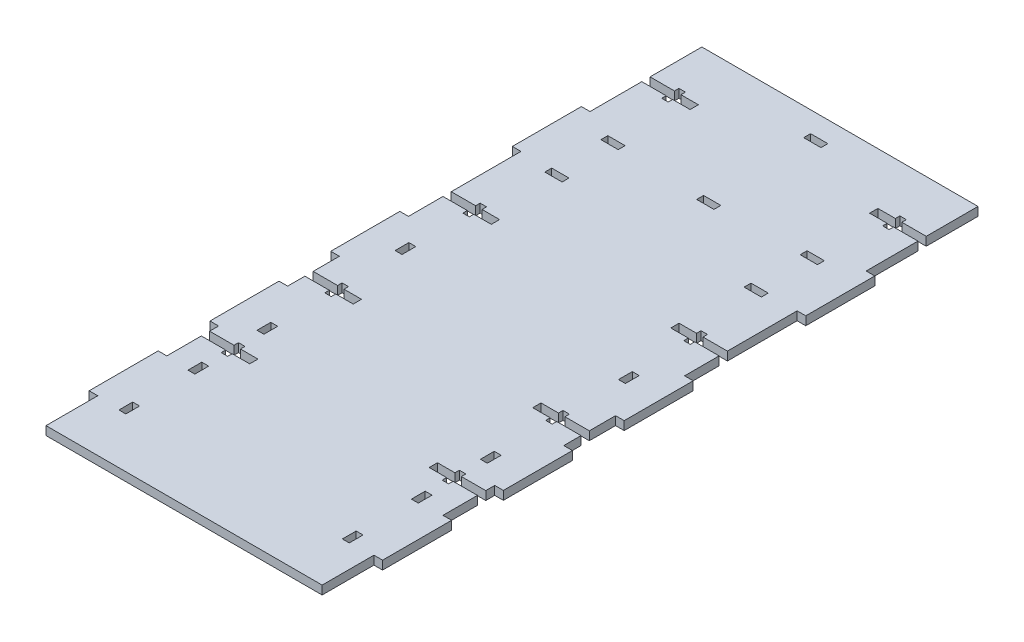
from build123d import *

# Parameters (mm, degrees)
SKETCH1_W           = 101.6
SKETCH1_H           = 241.3
BOSS_EXTRUDE1_DEPTH = 3.175
SKETCH2_W           = 2.54
SKETCH2_H           = 5.08
SKETCH2_W_2         = 6.35
SKETCH2_H_2         = 2.54
CUT_EXTRUDE1_DEPTH  = 6.35
SKETCH3_W           = 6.35
SKETCH3_H           = 25.4
BOSS_EXTRUDE2_DEPTH = 3.175


with BuildPart() as part:
    # Sketch1 → Boss-Extrude1 (new body)
    with BuildSketch(Plane(origin=(0, 0, 0), x_dir=(1, 0, 0), z_dir=(0, 1, 0))):
        with Locations((50.8, 120.65)):
            Rectangle(SKETCH1_W, SKETCH1_H)
    extrude(amount=BOSS_EXTRUDE1_DEPTH)

    # Sketch2 → Cut-Extrude1 (cut)
    with BuildSketch(Plane(origin=(0, 3.175, 0), x_dir=(1, 0, 0), z_dir=(0, 1, 0))):
        with Locations((9.698538564, 20.940235373)):
            Rectangle(SKETCH2_W, SKETCH2_H)
        with Locations((9.698538564, 46.340235373)):
            Rectangle(SKETCH2_W, SKETCH2_H)
        with Locations((9.698538564, 71.740235373)):
            Rectangle(SKETCH2_W, SKETCH2_H)
        with Locations((9.698538564, 122.540235373)):
            Rectangle(SKETCH2_W, SKETCH2_H)
        with Locations((14.143538564, 173.828614979)):
            Rectangle(SKETCH2_W_2, SKETCH2_H_2)
        with Locations((14.143538564, 194.471385021)):
            Rectangle(SKETCH2_W_2, SKETCH2_H_2)
        with Locations((50.8, 193.04)):
            Rectangle(SKETCH2_W_2, SKETCH2_H_2)
        with Locations((50.8, 232.41)):
            Rectangle(SKETCH2_W_2, SKETCH2_H_2)
        Polygon((8.969375, 60.198), (0, 60.198), (0, 57.15), (8.969375, 57.15), (8.969375, 55.499), (11.350625, 55.499), (11.350625, 57.15), (17.78, 57.15), (17.78, 60.198), (11.350625, 60.198), (11.350625, 61.849), (8.969375, 61.849), align=None)
        Polygon((8.969375, 98.298), (0, 98.298), (0, 95.25), (8.969375, 95.25), (8.969375, 93.599), (11.350625, 93.599), (11.350625, 95.25), (17.78, 95.25), (17.78, 98.298), (11.350625, 98.298), (11.350625, 99.949), (8.969375, 99.949), align=None)
        Polygon((8.969375, 149.098), (0, 149.098), (0, 146.05), (8.969375, 146.05), (8.969375, 144.399), (11.350625, 144.399), (11.350625, 146.05), (17.78, 146.05), (17.78, 149.098), (11.350625, 149.098), (11.350625, 150.749), (8.969375, 150.749), align=None)
        Polygon((8.969375, 222.25), (0, 222.25), (0, 219.202), (8.969375, 219.202), (8.969375, 217.551), (11.350625, 217.551), (11.350625, 219.202), (17.78, 219.202), (17.78, 222.25), (11.350625, 222.25), (11.350625, 223.901), (8.969375, 223.901), align=None)
        with Locations((91.901461436, 20.940235373)):
            Rectangle(SKETCH2_W, SKETCH2_H)
        Polygon((90.249375, 61.849), (90.249375, 60.198), (83.82, 60.198), (83.82, 57.15), (90.249375, 57.15), (90.249375, 55.499), (92.630625, 55.499), (92.630625, 57.15), (101.6, 57.15), (101.6, 60.198), (92.630625, 60.198), (92.630625, 61.849), align=None)
        with Locations((91.901461436, 46.340235373)):
            Rectangle(SKETCH2_W, SKETCH2_H)
        with Locations((91.901461436, 71.740235373)):
            Rectangle(SKETCH2_W, SKETCH2_H)
        Polygon((90.249375, 93.599), (92.630625, 93.599), (92.630625, 95.25), (101.6, 95.25), (101.6, 98.298), (92.630625, 98.298), (92.630625, 99.949), (90.249375, 99.949), (90.249375, 98.298), (83.82, 98.298), (83.82, 95.25), (90.249375, 95.25), align=None)
        with Locations((91.901461436, 122.540235373)):
            Rectangle(SKETCH2_W, SKETCH2_H)
        Polygon((90.249375, 144.399), (92.630625, 144.399), (92.630625, 146.05), (101.6, 146.05), (101.6, 149.098), (92.630625, 149.098), (92.630625, 150.749), (90.249375, 150.749), (90.249375, 149.098), (83.82, 149.098), (83.82, 146.05), (90.249375, 146.05), align=None)
        Polygon((90.249375, 219.202), (90.249375, 217.551), (92.630625, 217.551), (92.630625, 219.202), (101.6, 219.202), (101.6, 222.25), (92.630625, 222.25), (92.630625, 223.901), (90.249375, 223.901), (90.249375, 222.25), (83.82, 222.25), (83.82, 219.202), align=None)
        with Locations((87.456461436, 194.471385021)):
            Rectangle(SKETCH2_W_2, SKETCH2_H_2)
        with Locations((87.456461436, 173.828614979)):
            Rectangle(SKETCH2_W_2, SKETCH2_H_2)
    extrude(amount=-CUT_EXTRUDE1_DEPTH, mode=Mode.SUBTRACT)

    # Sketch3 → Boss-Extrude2 (add)
    with BuildSketch(Plane(origin=(0, 3.175, 0), x_dir=(1, 0, 0), z_dir=(0, 1, 0))):
        with Locations((0, 187.452)):
            Rectangle(SKETCH3_W, SKETCH3_H)
        with Locations((0, 120.65)):
            Rectangle(SKETCH3_W, SKETCH3_H)
        with Locations((0, 76.2)):
            Rectangle(SKETCH3_W, SKETCH3_H)
        with Locations((0, 31.75)):
            Rectangle(SKETCH3_W, SKETCH3_H)
        with Locations((101.6, 31.75)):
            Rectangle(SKETCH3_W, SKETCH3_H)
        with Locations((101.6, 76.2)):
            Rectangle(SKETCH3_W, SKETCH3_H)
        with Locations((101.6, 120.65)):
            Rectangle(SKETCH3_W, SKETCH3_H)
        with Locations((101.6, 187.452)):
            Rectangle(SKETCH3_W, SKETCH3_H)
    extrude(amount=-BOSS_EXTRUDE2_DEPTH)


solid = part.part
